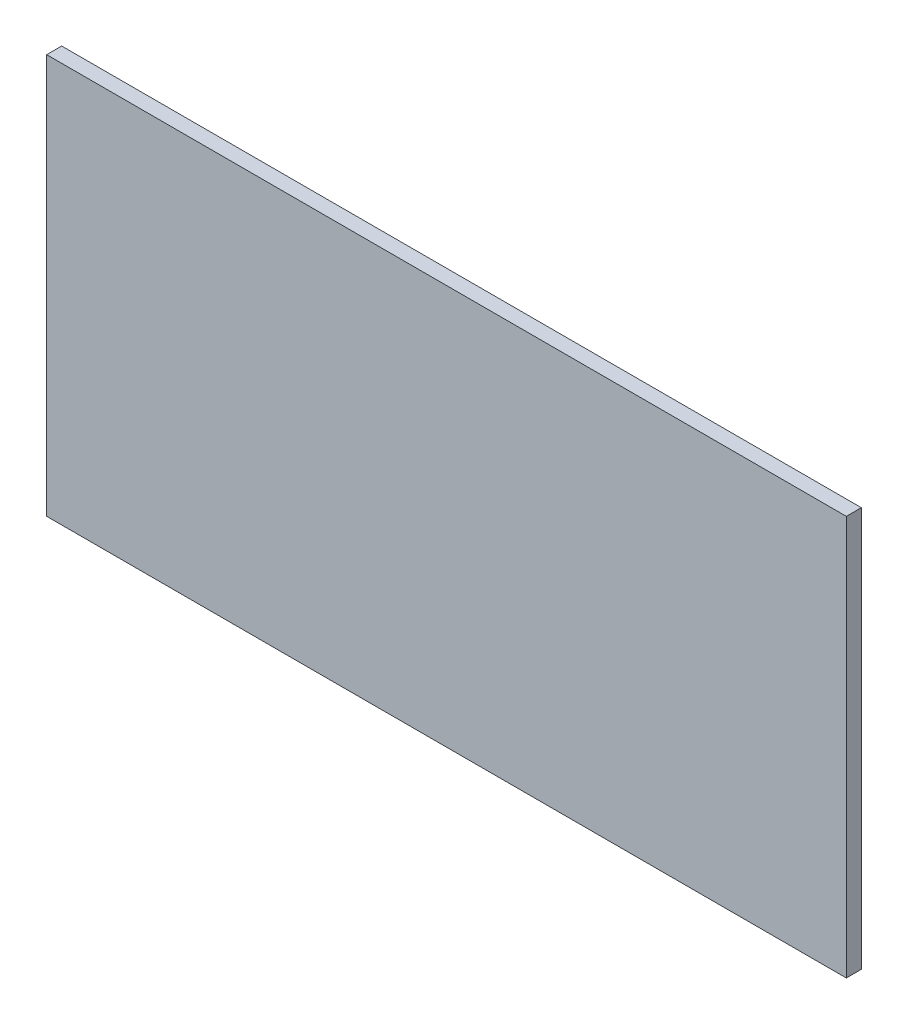
from build123d import *

# Parameters (mm, degrees)
SKETCH1_W           = 160
SKETCH1_H           = 80
BOSS_EXTRUDE1_DEPTH = 3


with BuildPart() as part:
    # Sketch1 → Boss-Extrude1 (new body)
    with BuildSketch(Plane.XY):
        with Locations((13.697388893, 4.936705045)):
            Rectangle(SKETCH1_W, SKETCH1_H)
    extrude(amount=BOSS_EXTRUDE1_DEPTH)


solid = part.part
